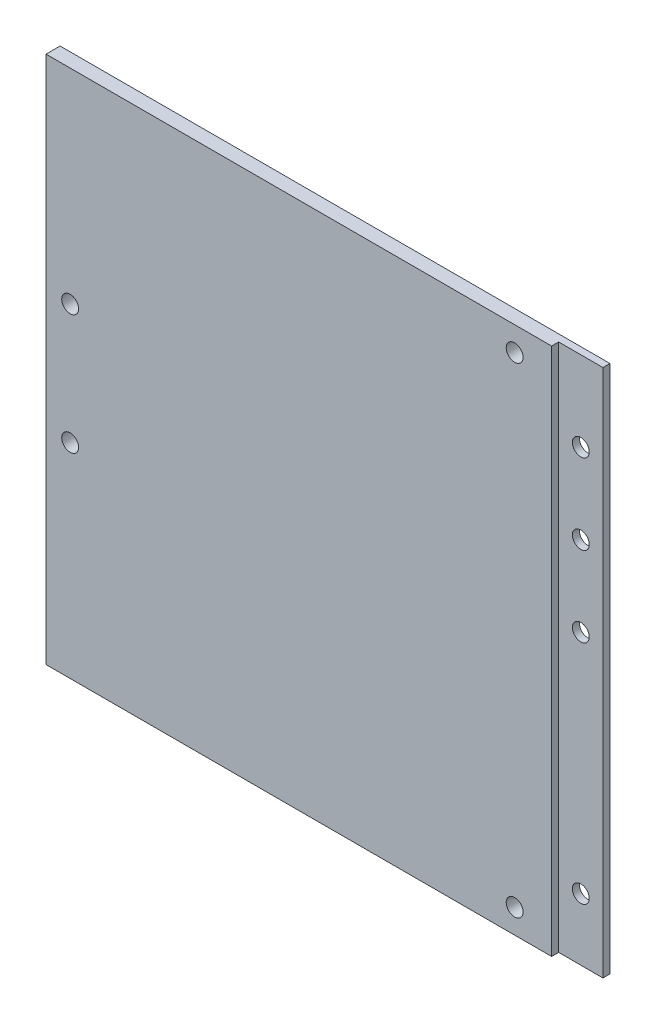
from build123d import *

# Parameters (mm, degrees)
SKETCH2_W           = 124.173
SKETCH2_H           = 119.38
BOSS_EXTRUDE1_DEPTH = 3.175
SKETCH4_R           = 1.905
CUT_EXTRUDE1_DEPTH  = 14.175
SKETCH10_W          = 1.59
SKETCH10_H          = 120
CUT_EXTRUDE3_DEPTH  = 10
SKETCH11_R          = 1.905
CUT_EXTRUDE4_DEPTH  = 10


with BuildPart() as part:
    # Sketch2 → Boss-Extrude1 (new body)
    with BuildSketch(Plane.XY):
        with Locations((40.767155738, -50.87039032)):
            Rectangle(SKETCH2_W, SKETCH2_H)
    extrude(amount=BOSS_EXTRUDE1_DEPTH)

    # Sketch4 → Cut-Extrude1 (cut)
    with BuildSketch(Plane.XY):
        with Locations((-15.867344262, -37.32039032)):
            Circle(SKETCH4_R)
        with Locations((-15.867344262, -64.42239032)):
            Circle(SKETCH4_R)
        with Locations((84.503655738, 3.36760968)):
            Circle(SKETCH4_R)
        with Locations((84.503655738, -105.10839032)):
            Circle(SKETCH4_R)
    extrude(amount=CUT_EXTRUDE1_DEPTH, mode=Mode.SUBTRACT)

    # Sketch10 → Cut-Extrude3 (cut)
    with BuildSketch(Plane(origin=(102.853655738, 0, 0), x_dir=(0, 0, -1), z_dir=(1, 0, 0))):
        with Locations((-2.380000064, -51.180389625)):
            Rectangle(SKETCH10_W, SKETCH10_H)
    extrude(amount=-CUT_EXTRUDE3_DEPTH, mode=Mode.SUBTRACT)

    # Sketch11 → Cut-Extrude4 (cut)
    with BuildSketch(Plane.XY.offset(1.585000064)):
        with Locations((97.853655738, -9.260389625)):
            Circle(SKETCH11_R)
        with Locations((97.853655738, -27.350389625)):
            Circle(SKETCH11_R)
        with Locations((97.853655738, -45.430389625)):
            Circle(SKETCH11_R)
        with Locations((97.853655738, -96.56039032)):
            Circle(SKETCH11_R)
    extrude(amount=-CUT_EXTRUDE4_DEPTH, mode=Mode.SUBTRACT)


solid = part.part
